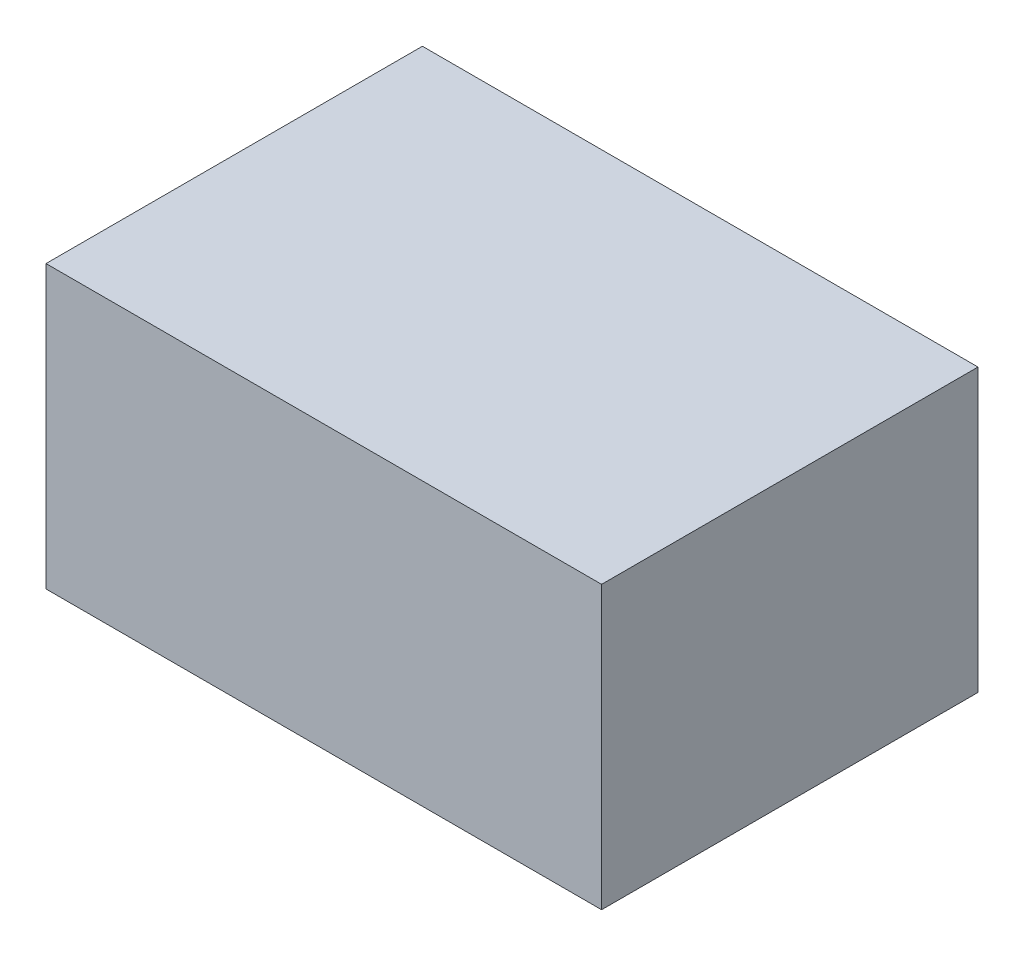
from build123d import *

# Parameters (mm, degrees)
SKIZZE1_W                       = 78.85495933
SKIZZE1_H                       = 53.42109464
AUFSATZ_LINEAR_AUSTRAGEN2_DEPTH = 20


with BuildPart() as part:
    # Skizze1 → Aufsatz-Linear austragen2 (new body, symmetric)
    with BuildSketch(Plane(origin=(0, 0, 0), x_dir=(1, 0, 0), z_dir=(0, 1, 0))):
        Rectangle(SKIZZE1_W, SKIZZE1_H)
    extrude(amount=AUFSATZ_LINEAR_AUSTRAGEN2_DEPTH, both=True)


solid = part.part
